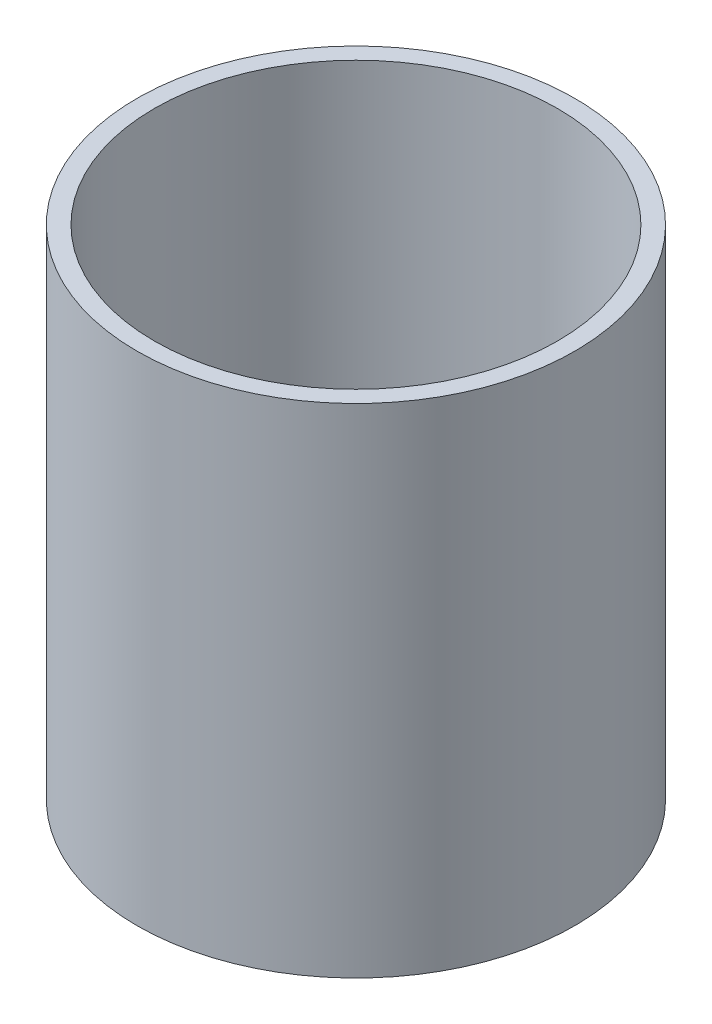
from build123d import *

# Parameters (mm, degrees)
SKETCH1_R           = 22
SKETCH1_R_2         = 20.25
BOSS_EXTRUDE1_DEPTH = 50


with BuildPart() as part:
    # Sketch1 → Boss-Extrude1 (new body)
    with BuildSketch(Plane(origin=(0, 0, 0), x_dir=(1, 0, 0), z_dir=(0, 1, 0))):
        Circle(SKETCH1_R)
        Circle(SKETCH1_R_2, mode=Mode.SUBTRACT)
    extrude(amount=BOSS_EXTRUDE1_DEPTH)


solid = part.part
